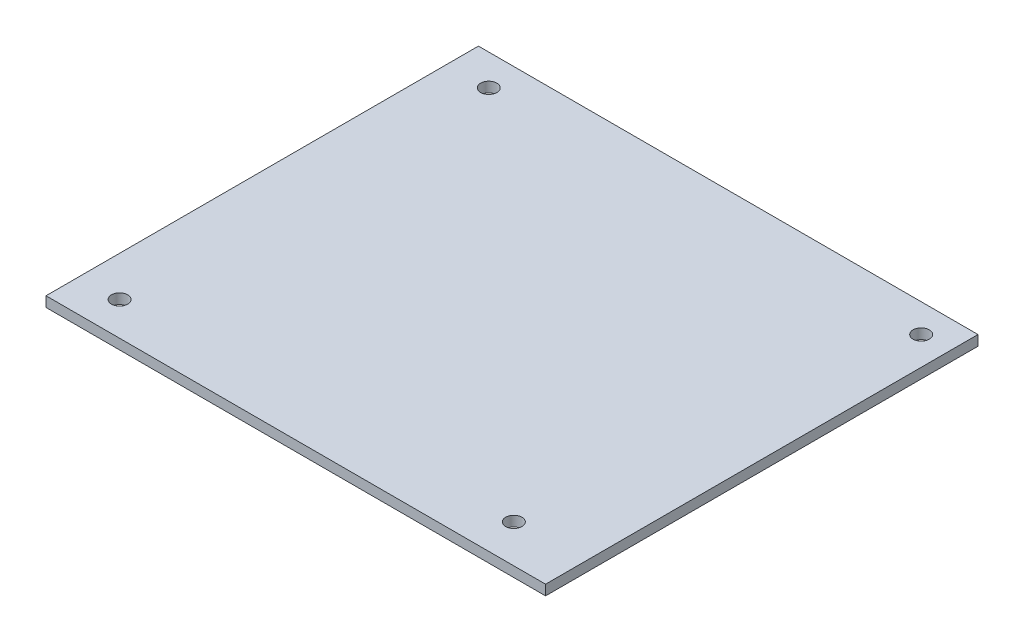
from build123d import *

# Parameters (mm, degrees)
SKETCH1_W           = 98.298
SKETCH1_H           = 85.09
SKETCH1_R           = 1.6
BOSS_EXTRUDE1_DEPTH = 2


with BuildPart() as part:
    # Sketch1 → Boss-Extrude1 (new body)
    with BuildSketch(Plane(origin=(0, 0, 0), x_dir=(1, 0, 0), z_dir=(0, 1, 0))):
        Rectangle(SKETCH1_W, SKETCH1_H)
        with Locations((-41.021, 36.449)):
            Circle(SKETCH1_R, mode=Mode.SUBTRACT)
        with Locations((43.561, 36.957)):
            Circle(SKETCH1_R, mode=Mode.SUBTRACT)
        with Locations((35.41456657, -35.057323722)):
            Circle(SKETCH1_R, mode=Mode.SUBTRACT)
        with Locations((-41.275, -35.941)):
            Circle(SKETCH1_R, mode=Mode.SUBTRACT)
    extrude(amount=BOSS_EXTRUDE1_DEPTH)


solid = part.part
